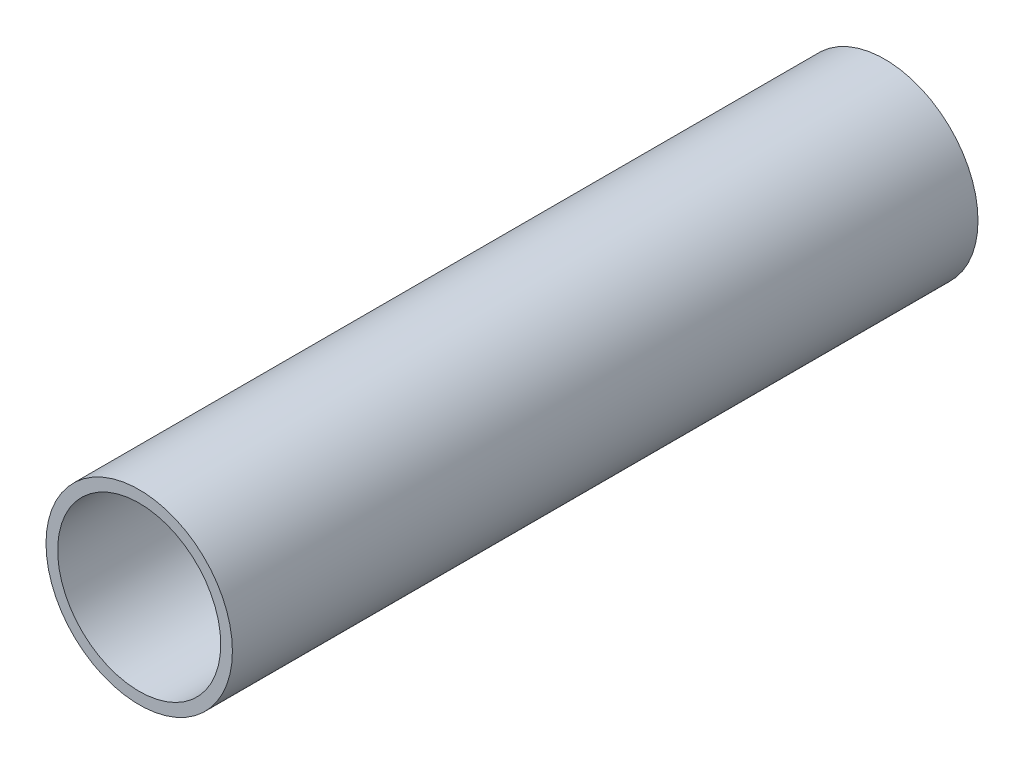
from build123d import *

# Parameters (mm, degrees)
SKETCH1_R           = 12.7
SKETCH1_R_2         = 11.1125
BOSS_EXTRUDE1_DEPTH = 101.6


with BuildPart() as part:
    # Sketch1 → Boss-Extrude1 (new body)
    with BuildSketch(Plane.XY):
        Circle(SKETCH1_R)
        Circle(SKETCH1_R_2, mode=Mode.SUBTRACT)
    extrude(amount=BOSS_EXTRUDE1_DEPTH)


solid = part.part
